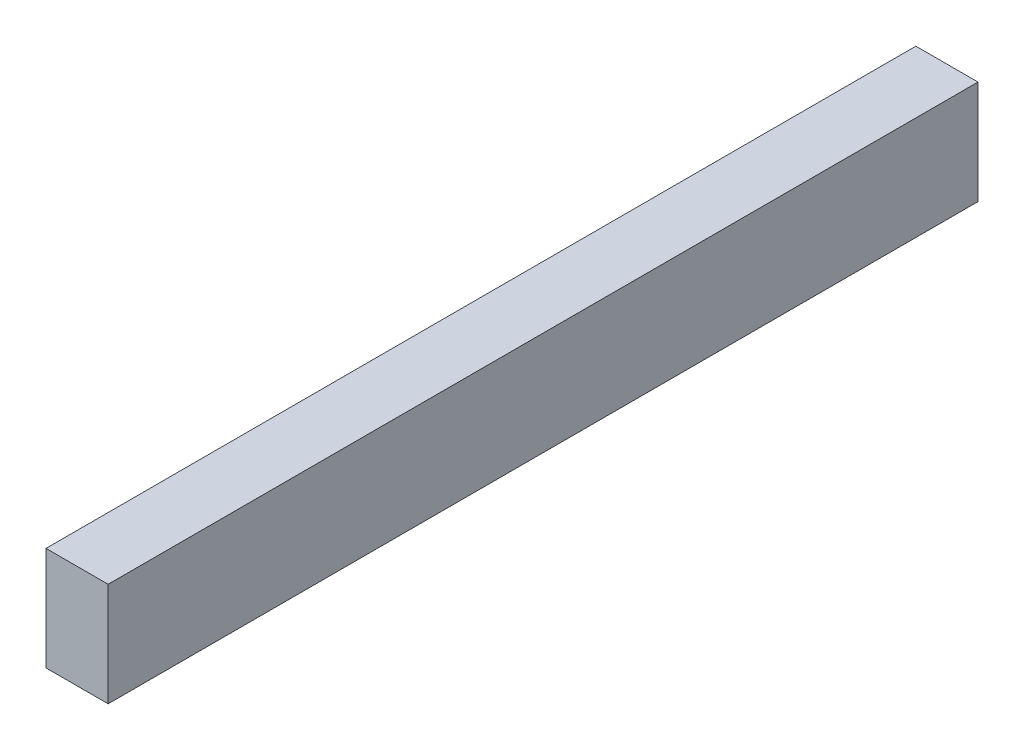
from build123d import *

# Parameters (mm, degrees)
SKETCH1_W           = 38.1
SKETCH1_H           = 63.5
BOSS_EXTRUDE1_DEPTH = 533.4


with BuildPart() as part:
    # Sketch1 → Boss-Extrude1 (new body)
    with BuildSketch(Plane.XY):
        Rectangle(SKETCH1_W, SKETCH1_H)
    extrude(amount=BOSS_EXTRUDE1_DEPTH)


solid = part.part
